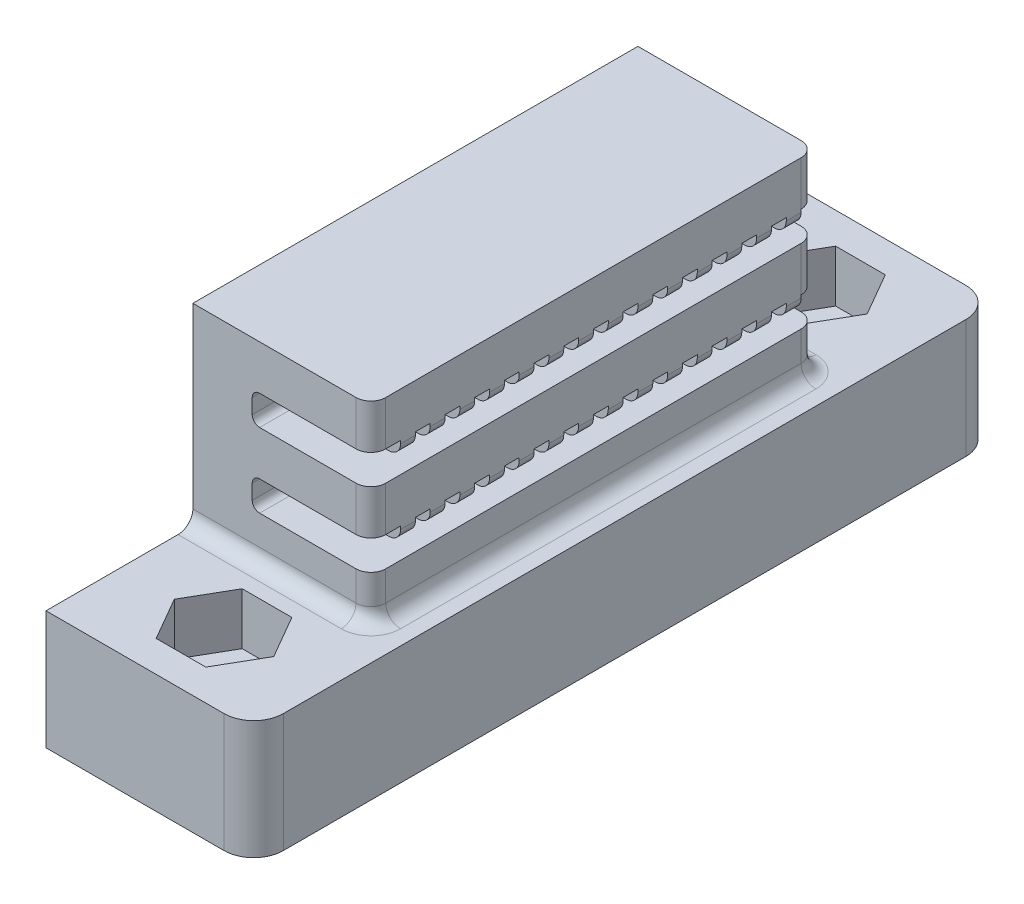
from build123d import *

# Parameters (mm, degrees)
CROQUIS1_W              = 14
CROQUIS1_H              = 50
CROQUIS1_R              = 1.55
SALIENTE_EXTRUIR1_DEPTH = 8
CORTAR_EXTRUIR1_DEPTH   = 3.5
CROQUIS3_W              = 14
CROQUIS3_H              = 30
SALIENTE_EXTRUIR3_DEPTH = 13
CORTAR_EXTRUIR2_DEPTH   = 10
CROQUIS5_W              = 30
CROQUIS5_H              = 13
CORTAR_EXTRUIR3_DEPTH   = 2
REDONDEO1_R             = 0.8
REDONDEO2_R             = 2
REDONDEO3_R             = 1
REDONDEO4_R             = 1
REDONDEO5_R             = 0.5


with BuildPart() as part:
    # Croquis1 → Saliente-Extruir1 (new body)
    with BuildSketch(Plane(origin=(0, 0, 0), x_dir=(1, 0, 0), z_dir=(0, 1, 0))):
        with Locations((7, 25)):
            Rectangle(CROQUIS1_W, CROQUIS1_H)
        with Locations((7, 45)):
            Circle(CROQUIS1_R, mode=Mode.SUBTRACT)
        with Locations((7, 5)):
            Circle(CROQUIS1_R, mode=Mode.SUBTRACT)
    extrude(amount=SALIENTE_EXTRUIR1_DEPTH)

    # Croquis2 → Cortar-Extruir1 (cut)
    with BuildSketch(Plane(origin=(0, 8, 0), x_dir=(1, 0, 0), z_dir=(0, 1, 0))):
        Polygon((10.348631561, 45), (8.674315781, 47.9), (5.325684219, 47.9), (3.651368439, 45), (5.325684219, 42.1), (8.674315781, 42.1), align=None)
        Polygon((10.348631561, 5), (8.674315781, 7.9), (5.325684219, 7.9), (3.651368439, 5), (5.325684219, 2.1), (8.674315781, 2.1), align=None)
    extrude(amount=-CORTAR_EXTRUIR1_DEPTH, mode=Mode.SUBTRACT)

    # Croquis3 → Saliente-Extruir3 (add)
    with BuildSketch(Plane(origin=(0, 8, 0), x_dir=(1, 0, 0), z_dir=(0, 1, 0))):
        with Locations((7, 24.9)):
            Rectangle(CROQUIS3_W, CROQUIS3_H)
    extrude(amount=SALIENTE_EXTRUIR3_DEPTH)

    # Croquis4 → Cortar-Extruir2 (cut)
    with BuildSketch(Plane(origin=(14, 0, 0), x_dir=(0, 0, -1), z_dir=(1, 0, 0))):
        Polygon((39.9, 18), (38.9, 18), (38.9, 17), (37.9, 17), (37.9, 18), (36.9, 18), (36.9, 17), (35.9, 17), (35.9, 18), (34.9, 18), (34.9, 17), (33.9, 17), (33.9, 18), (32.9, 18), (32.9, 17), (31.9, 17), (31.9, 18), (30.9, 18), (30.9, 17), (29.9, 17), (29.9, 18), (28.9, 18), (28.9, 17), (27.9, 17), (27.9, 18), (26.9, 18), (26.9, 17), (25.9, 17), (25.9, 18), (24.9, 18), (24.9, 17), (23.9, 17), (23.9, 18), (22.9, 18), (22.9, 17), (21.9, 17), (21.9, 18), (20.9, 18), (20.9, 17), (19.9, 17), (19.9, 18), (18.9, 18), (18.9, 17), (17.9, 17), (17.9, 18), (16.9, 18), (16.9, 17), (15.9, 17), (15.9, 18), (14.9, 18), (14.9, 17), (13.9, 17), (13.9, 18), (12.9, 18), (12.9, 17), (11.9, 17), (11.9, 18), (9.9, 18), (9.9, 16), (39.9, 16), align=None)
        Polygon((39.9, 13), (38.9, 13), (38.9, 12), (37.9, 12), (37.9, 13), (36.9, 13), (36.9, 12), (35.9, 12), (35.9, 13), (34.9, 13), (34.9, 12), (33.9, 12), (33.9, 13), (32.9, 13), (32.9, 12), (31.9, 12), (31.9, 13), (30.9, 13), (30.9, 12), (29.9, 12), (29.9, 13), (28.9, 13), (28.9, 12), (27.9, 12), (27.9, 13), (26.9, 13), (26.9, 12), (25.9, 12), (25.9, 13), (24.9, 13), (24.9, 12), (23.9, 12), (23.9, 13), (22.9, 13), (22.9, 12), (21.9, 12), (21.9, 13), (20.9, 13), (20.9, 12), (19.9, 12), (19.9, 13), (18.9, 13), (18.9, 12), (17.9, 12), (17.9, 13), (16.9, 13), (16.9, 12), (15.9, 12), (15.9, 13), (14.9, 13), (14.9, 12), (13.9, 12), (13.9, 13), (12.9, 13), (12.9, 12), (11.9, 12), (11.9, 13), (9.9, 13), (9.9, 11), (39.9, 11), align=None)
    extrude(amount=-CORTAR_EXTRUIR2_DEPTH, mode=Mode.SUBTRACT)

    # Croquis5 → Cortar-Extruir3 (cut)
    with BuildSketch(Plane(origin=(14, 0, 0), x_dir=(0, 0, -1), z_dir=(1, 0, 0))):
        with Locations((24.9, 14.5)):
            Rectangle(CROQUIS5_W, CROQUIS5_H)
    extrude(amount=-CORTAR_EXTRUIR3_DEPTH, mode=Mode.SUBTRACT)

    # Redondeo1
    redondeo1_edges = [part.edges().sort_by_distance(p)[0] for p in [
        (12, 12, -12.4),
        (12, 12, -14.4),
        (12, 12, -16.4),
        (12, 12, -18.4),
        (12, 12, -20.4),
        (12, 12, -22.4),
        (12, 12, -24.4),
        (12, 12, -26.4),
        (12, 12, -28.4),
        (12, 12, -30.4),
        (12, 12, -32.4),
        (12, 12, -34.4),
        (12, 12, -36.4),
        (12, 12, -38.4),
        (12, 17, -12.4),
        (12, 17, -14.4),
        (12, 17, -16.4),
        (12, 17, -18.4),
        (12, 17, -20.4),
        (12, 17, -22.4),
        (12, 17, -24.4),
        (12, 17, -26.4),
        (12, 17, -28.4),
        (12, 17, -30.4),
        (12, 17, -32.4),
        (12, 17, -34.4),
        (12, 17, -36.4),
        (12, 17, -38.4),
    ]]
    fillet(redondeo1_edges, radius=REDONDEO1_R)

    # Redondeo2
    redondeo2_edges = [part.edges().sort_by_distance(p)[0] for p in [
        (14, 4, -50),
        (14, 4, 0),
    ]]
    fillet(redondeo2_edges, radius=REDONDEO2_R)

    # Redondeo3
    redondeo3_edges = [part.edges().sort_by_distance(p)[0] for p in [
        (12, 9.5, -9.9),
        (12, 14.5, -9.9),
        (12, 19.5, -9.9),
        (12, 9.5, -39.9),
        (12, 14.5, -39.9),
        (12, 19.5, -39.9),
    ]]
    fillet(redondeo3_edges, radius=REDONDEO3_R)

    # Redondeo4
    redondeo4_edges = [part.edges().sort_by_distance(p)[0] for p in [
        (5.5, 8, -9.9),
        (5.5, 8, -39.9),
        (12, 8, -24.9),
        (11.707106781, 8, -39.607106781),
        (11.707106781, 8, -10.192893219),
    ]]
    fillet(redondeo4_edges, radius=REDONDEO4_R)

    # Redondeo5
    redondeo5_edges = [part.edges().sort_by_distance(p)[0] for p in [
        (4, 16, -24.9),
        (4, 18, -10.9),
        (4, 18, -13.4),
        (4, 18, -15.4),
        (4, 18, -17.4),
        (4, 18, -19.4),
        (4, 18, -21.4),
        (4, 18, -23.4),
        (4, 18, -25.4),
        (4, 18, -27.4),
        (4, 18, -29.4),
        (4, 18, -31.4),
        (4, 18, -33.4),
        (4, 18, -35.4),
        (4, 18, -37.4),
        (4, 18, -39.4),
        (4, 11, -24.9),
        (4, 13, -10.9),
        (4, 13, -13.4),
        (4, 13, -15.4),
        (4, 13, -17.4),
        (4, 13, -19.4),
        (4, 13, -21.4),
        (4, 13, -23.4),
        (4, 13, -25.4),
        (4, 13, -27.4),
        (4, 13, -29.4),
        (4, 13, -31.4),
        (4, 13, -33.4),
        (4, 13, -35.4),
        (4, 13, -37.4),
        (4, 13, -39.4),
    ]]
    fillet(redondeo5_edges, radius=REDONDEO5_R)


solid = part.part
